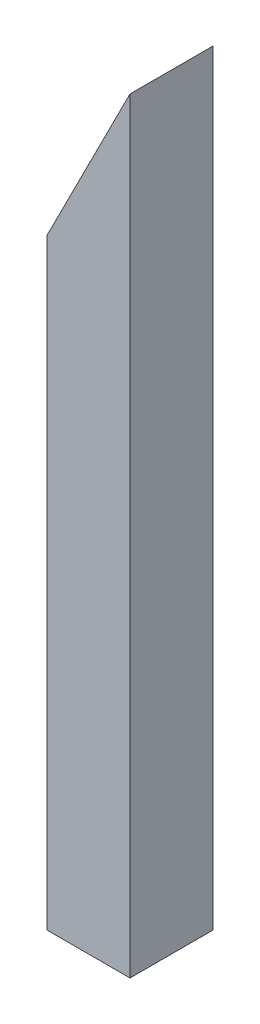
from build123d import *

# Parameters (mm, degrees)
BOSS_EXTRUDE1_DEPTH     = 203.2
SKETCH2_W               = 165.1
SKETCH2_H               = 165.1
CUT_EXTRUDE1_DEPTH      = 1
CUT_EXTRUDE1_DEPTH_BACK = 1874.504


with BuildPart() as part:
    # Sketch1 → Boss-Extrude1 (new body)
    with BuildSketch(Plane.XY):
        Polygon((0, 0), (203.2, 0), (203.2, 1873.504), (0, 1472.107144898), align=None)
    extrude(amount=BOSS_EXTRUDE1_DEPTH)

    # Sketch2 → Cut-Extrude1 (cut, two sides)
    with BuildSketch(Plane.XZ) as cut_extrude1_sk:
        with Locations((101.6, 101.6)):
            Rectangle(SKETCH2_W, SKETCH2_H)
    extrude(amount=CUT_EXTRUDE1_DEPTH, mode=Mode.SUBTRACT)
    extrude(cut_extrude1_sk.sketch, amount=-CUT_EXTRUDE1_DEPTH_BACK, mode=Mode.SUBTRACT)


solid = part.part
